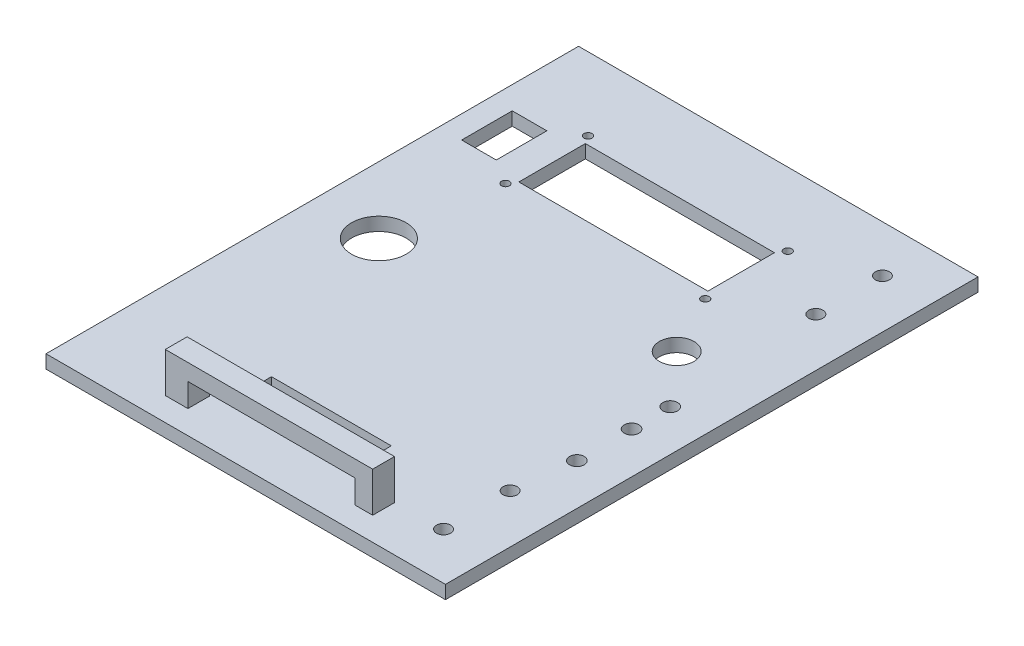
from build123d import *

# Parameters (mm, degrees)
SKETCH1_W           = 150
SKETCH1_H           = 200
BOSS_EXTRUDE1_DEPTH = 5
CUT_EXTRUDE1_REACH  = 7
SKETCH2_R           = 10.25
SKETCH2_R_2         = 2.65
SKETCH3_R           = 1.5
SKETCH3_R_2         = 6.5
SKETCH3_R_3         = 2.75
SKETCH3_W           = 71
SKETCH3_H           = 25
SKETCH3_W_2         = 45
SKETCH3_H_2         = 5
SKETCH3_W_3         = 13
SKETCH3_H_3         = 19
CUT_EXTRUDE2_DEPTH  = 10
SKETCH4_W           = 77.871217223
SKETCH4_H           = 8.196970234
BOSS_EXTRUDE2_DEPTH = 15
SKETCH5_W           = 62.74414778
SKETCH5_H           = 8.82586267
CUT_EXTRUDE3_DEPTH  = 15


with BuildPart() as part:
    # Sketch1 → Boss-Extrude1 (new body)
    with BuildSketch(Plane(origin=(0, 0, 0), x_dir=(1, 0, 0), z_dir=(0, 1, 0))):
        Rectangle(SKETCH1_W, SKETCH1_H)
    extrude(amount=BOSS_EXTRUDE1_DEPTH)

    # Sketch2 → Cut-Extrude1 (cut, up to next)
    with BuildSketch(Plane(origin=(0, 5, 0), x_dir=(1, 0, 0), z_dir=(0, 1, 0)), mode=Mode.PRIVATE) as cut_extrude1_sk1:
        with Locations((-50, 0)):
            Circle(SKETCH2_R)
    cut_extrude1_tool1 = extrude(cut_extrude1_sk1.sketch, amount=-CUT_EXTRUDE1_REACH, mode=Mode.PRIVATE) & part.part
    add(cut_extrude1_tool1.solids().sort_by_distance((-50, 5, 0))[0], mode=Mode.SUBTRACT)
    # Sketch2 → Cut-Extrude1 (cut, up to next)
    with BuildSketch(Plane(origin=(0, 5, 0), x_dir=(1, 0, 0), z_dir=(0, 1, 0)), mode=Mode.PRIVATE) as cut_extrude1_sk2:
        with Locations((56.7, 82.4)):
            Circle(SKETCH2_R_2)
    cut_extrude1_tool2 = extrude(cut_extrude1_sk2.sketch, amount=-CUT_EXTRUDE1_REACH, mode=Mode.PRIVATE) & part.part
    add(cut_extrude1_tool2.solids().sort_by_distance((56.7, 5, -82.4))[0], mode=Mode.SUBTRACT)
    # Sketch2 → Cut-Extrude1 (cut, up to next)
    with BuildSketch(Plane(origin=(0, 5, 0), x_dir=(1, 0, 0), z_dir=(0, 1, 0)), mode=Mode.PRIVATE) as cut_extrude1_sk3:
        with Locations((56.7, 57.4)):
            Circle(SKETCH2_R_2)
    cut_extrude1_tool3 = extrude(cut_extrude1_sk3.sketch, amount=-CUT_EXTRUDE1_REACH, mode=Mode.PRIVATE) & part.part
    add(cut_extrude1_tool3.solids().sort_by_distance((56.7, 5, -57.4))[0], mode=Mode.SUBTRACT)
    # Sketch2 → Cut-Extrude1 (cut, up to next)
    with BuildSketch(Plane(origin=(0, 5, 0), x_dir=(1, 0, 0), z_dir=(0, 1, 0)), mode=Mode.PRIVATE) as cut_extrude1_sk4:
        with Locations((56.7, -57.4)):
            Circle(SKETCH2_R_2)
    cut_extrude1_tool4 = extrude(cut_extrude1_sk4.sketch, amount=-CUT_EXTRUDE1_REACH, mode=Mode.PRIVATE) & part.part
    add(cut_extrude1_tool4.solids().sort_by_distance((56.7, 5, 57.4))[0], mode=Mode.SUBTRACT)
    # Sketch2 → Cut-Extrude1 (cut, up to next)
    with BuildSketch(Plane(origin=(0, 5, 0), x_dir=(1, 0, 0), z_dir=(0, 1, 0)), mode=Mode.PRIVATE) as cut_extrude1_sk5:
        with Locations((56.7, -82.4)):
            Circle(SKETCH2_R_2)
    cut_extrude1_tool5 = extrude(cut_extrude1_sk5.sketch, amount=-CUT_EXTRUDE1_REACH, mode=Mode.PRIVATE) & part.part
    add(cut_extrude1_tool5.solids().sort_by_distance((56.7, 5, 82.4))[0], mode=Mode.SUBTRACT)

    # Sketch3 → Cut-Extrude2 (cut)
    with BuildSketch(Plane(origin=(0, 5, 0), x_dir=(1, 0, 0), z_dir=(0, 1, 0))):
        with Locations((-44.086851081, 72.644212882)):
            Circle(SKETCH3_R)
        with Locations((-44.086851081, 41.644212882)):
            Circle(SKETCH3_R)
        with Locations((30.913148919, 72.644212882)):
            Circle(SKETCH3_R)
        with Locations((30.913148919, 41.644212882)):
            Circle(SKETCH3_R)
        with Locations((42.666816073, 19.175055369)):
            Circle(SKETCH3_R_2)
        with Locations((59.428143187, 0)):
            Circle(SKETCH3_R_3)
        with Locations((59.428143187, -14.52369357)):
            Circle(SKETCH3_R_3)
        with Locations((59.428143187, -35.082227639)):
            Circle(SKETCH3_R_3)
        with Locations((-6.586851081, 57.144212882)):
            Rectangle(SKETCH3_W, SKETCH3_H)
        with Locations((-2.709269151, -67.613370395)):
            Rectangle(SKETCH3_W_2, SKETCH3_H_2)
        with Locations((-59.961970151, 57.054006432)):
            Rectangle(SKETCH3_W_3, SKETCH3_H_3)
    extrude(amount=-CUT_EXTRUDE2_DEPTH, mode=Mode.SUBTRACT)

    # Sketch4 → Boss-Extrude2 (add)
    with BuildSketch(Plane(origin=(0, 5, 0), x_dir=(1, 0, 0), z_dir=(0, 1, 0))):
        with Locations((-0.074528718, -87.092808737)):
            Rectangle(SKETCH4_W, SKETCH4_H)
    extrude(amount=BOSS_EXTRUDE2_DEPTH)

    # Sketch5 → Cut-Extrude3 (cut)
    with BuildSketch(Plane.XY.offset(91.191293854)):
        with Locations((0.850191704, 9.412931335)):
            Rectangle(SKETCH5_W, SKETCH5_H)
    extrude(amount=-CUT_EXTRUDE3_DEPTH, mode=Mode.SUBTRACT)


solid = part.part
